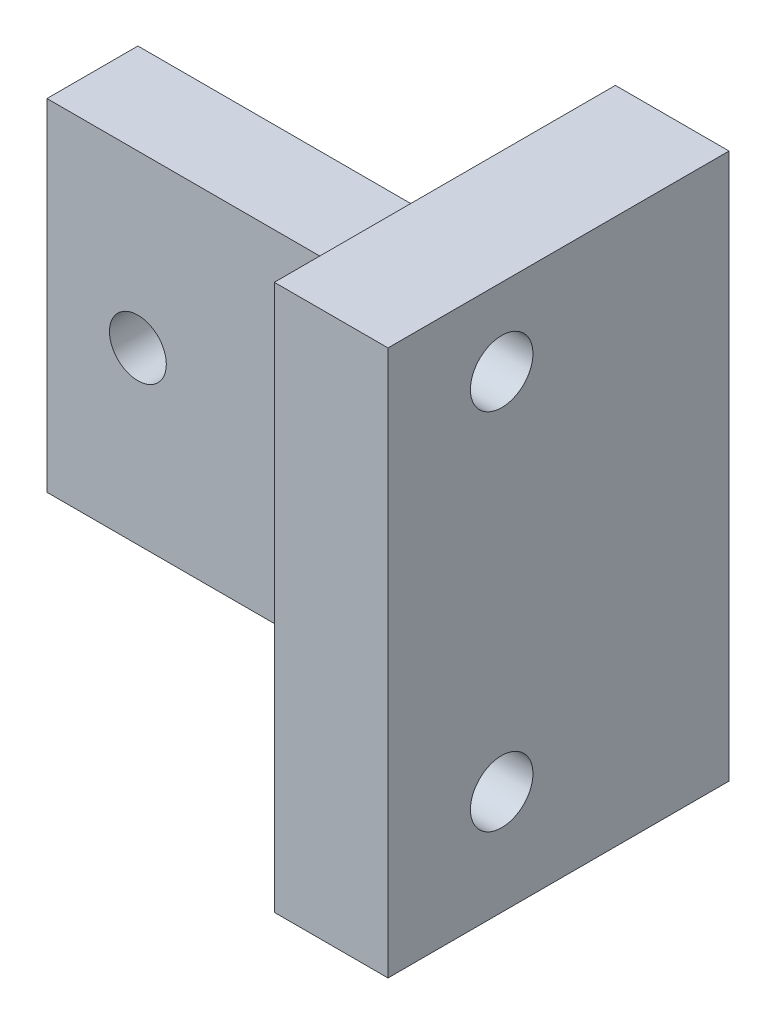
from build123d import *

# Parameters (mm, degrees)
SKETCH1_W             = 42
SKETCH1_H             = 30
BOSS_EXTRUDE1_DEPTH   = 8
BOSS_EXTRUDE1_2_DEPTH = 8
BOSS_EXTRUDE2_DEPTH   = 30
SKETCH2_R             = 2.5
CUT_EXTRUDE1_DEPTH    = 8
SKETCH3_R             = 2.75
CUT_EXTRUDE2_DEPTH    = 10
SKETCH4_W             = 30
SKETCH4_H             = 100
CUT_EXTRUDE3_DEPTH    = 52


with BuildPart() as part:
    # Sketch1 → Boss-Extrude1 (new body)
    with BuildSketch(Plane.XY):
        with Locations((21, 133)):
            Rectangle(SKETCH1_W, SKETCH1_H)
    extrude(amount=BOSS_EXTRUDE1_DEPTH)



with BuildPart() as body_2:
    # Sketch1 → Boss-Extrude1 2 (new body)
    with BuildSketch(Plane.XY):
        with Locations((21, 15)):
            Rectangle(SKETCH1_W, SKETCH1_H)
    extrude(amount=BOSS_EXTRUDE1_2_DEPTH)


with BuildPart() as part_1:
    add(part.part)

    add(body_2.part)  # Boss-Extrude2 merges body 2
    # Sketch1_3 → Boss-Extrude2 (add)
    with BuildSketch(Plane.XY):
        Polygon((42, 30), (42, 0), (52, 0), (52, 148), (42, 148), (42, 118), align=None)
    extrude(amount=BOSS_EXTRUDE2_DEPTH)

    # Sketch2 → Cut-Extrude1 (cut)
    with BuildSketch(Plane.XY.offset(8)):
        with Locations((8, 133)):
            Circle(SKETCH2_R)
        with Locations((34, 133)):
            Circle(SKETCH2_R)
        with Locations((34, 15)):
            Circle(SKETCH2_R)
        with Locations((8, 15)):
            Circle(SKETCH2_R)
    extrude(amount=-CUT_EXTRUDE1_DEPTH, mode=Mode.SUBTRACT)

    # Sketch3 → Cut-Extrude2 (cut)
    with BuildSketch(Plane(origin=(52, 0, 0), x_dir=(0, 0, -1), z_dir=(1, 0, 0))):
        with Locations((-20, 138.3)):
            Circle(SKETCH3_R)
        with Locations((-20, 106.3)):
            Circle(SKETCH3_R)
        with Locations((-20, 41.2)):
            Circle(SKETCH3_R)
        with Locations((-20, 9.2)):
            Circle(SKETCH3_R)
    extrude(amount=-CUT_EXTRUDE2_DEPTH, mode=Mode.SUBTRACT)

    # Sketch4 → Cut-Extrude3 (cut)
    with BuildSketch(Plane(origin=(52, 0, 0), x_dir=(0, 0, -1), z_dir=(1, 0, 0))):
        with Locations((-15, 98)):
            Rectangle(SKETCH4_W, SKETCH4_H)
    extrude(amount=-CUT_EXTRUDE3_DEPTH, mode=Mode.SUBTRACT)


solid = part_1.part
